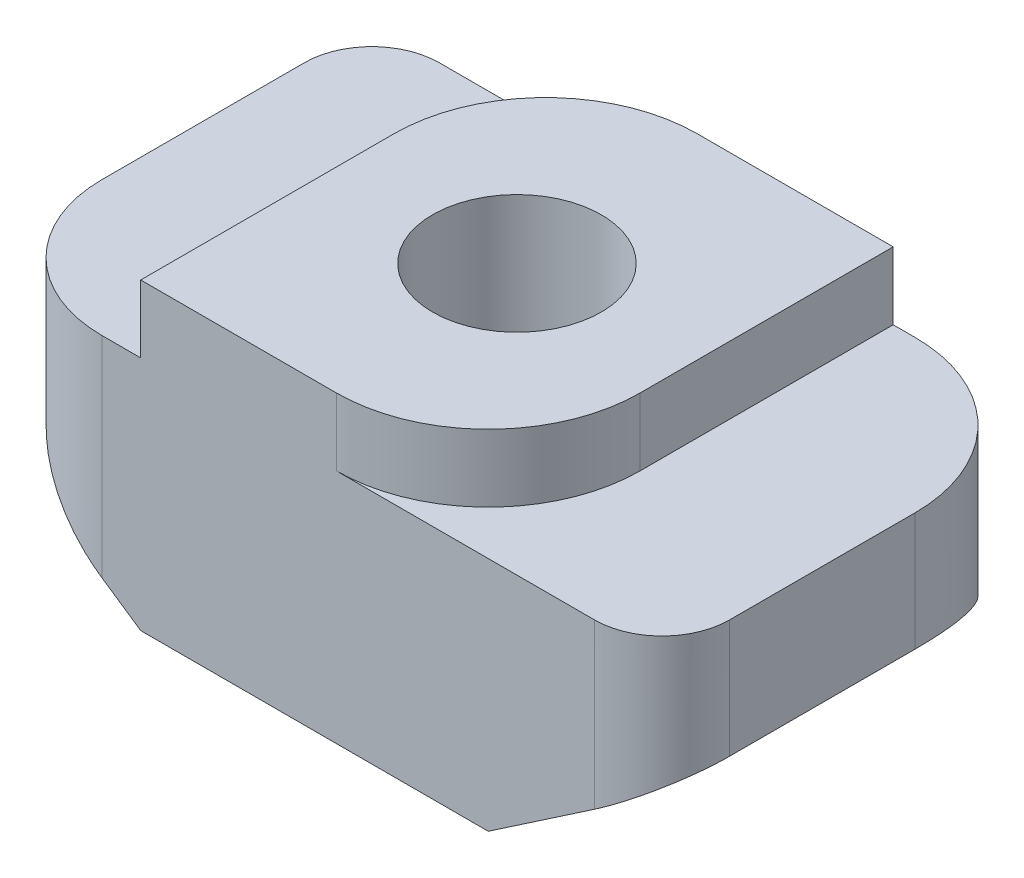
from build123d import *

# Parameters (mm, degrees)
BOSS_EXTRUDE1_DEPTH   = 6
M3X0_5_TAPPED_HOLE1_D = 2.5
FILLET1_R             = 1
FILLET2_R             = 2
FILLET3_R             = 1
FILLET4_R             = 2.25
FILLET5_R             = 2.25


with BuildPart() as part:
    # Sketch1 → Boss-Extrude1 (new body)
    with BuildSketch(Plane.XY):
        Polygon((-5.15, 1.75), (-2.575, 1.75), (-2.575, 2.75), (2.575, 2.75), (2.575, 1.75), (5.15, 1.75), (5.15, 0), (2.575, -1.75), (-2.575, -1.75), (-5.15, 0), align=None)
    extrude(amount=BOSS_EXTRUDE1_DEPTH)

    # M3x0.5 Tapped Hole1 (through all)
    with Locations(Plane(origin=(0, 2.75, 0), x_dir=(1, 0, 0), z_dir=(0, 1, 0))):
        with Locations((0, -3)):
            Hole(M3X0_5_TAPPED_HOLE1_D / 2)

    # Fillet1
    fillet1_edges = [part.edges().sort_by_distance(p)[0] for p in [
        (-5.15, 0.875, 0),
    ]]
    fillet(fillet1_edges, radius=FILLET1_R)

    # Fillet2
    fillet2_edges = [part.edges().sort_by_distance(p)[0] for p in [
        (-5.15, 0.875, 6),
    ]]
    fillet(fillet2_edges, radius=FILLET2_R)

    # Fillet3
    fillet3_edges = [part.edges().sort_by_distance(p)[0] for p in [
        (5.15, 0.875, 6),
    ]]
    fillet(fillet3_edges, radius=FILLET3_R)

    # Fillet4
    fillet4_edges = [part.edges().sort_by_distance(p)[0] for p in [
        (5.15, 0.875, 0),
    ]]
    fillet(fillet4_edges, radius=FILLET4_R)

    # Fillet5
    fillet5_edges = [part.edges().sort_by_distance(p)[0] for p in [
        (-2.575, 2.25, 0),
        (2.575, 2.25, 6),
    ]]
    fillet(fillet5_edges, radius=FILLET5_R)


solid = part.part
